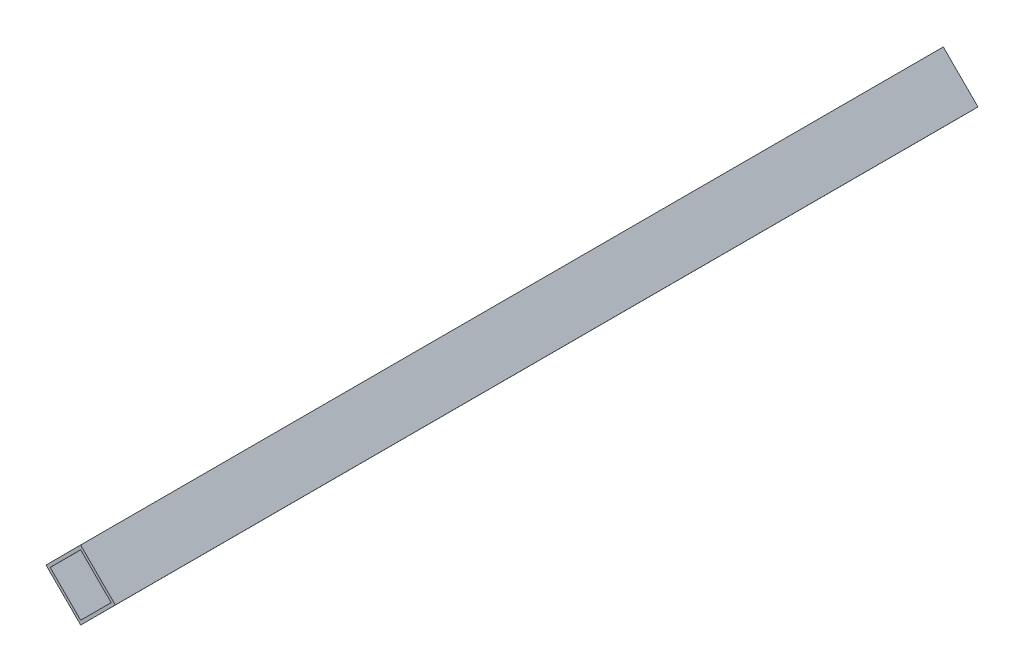
from build123d import *

# Parameters (mm, degrees)
EXTRUDE_1_DEPTH = 440


with BuildPart() as part:
    # 草圖1 → 填料-伸長1 (new body)
    with BuildSketch(Plane.XY):
        Polygon((0, 0), (17.69379362, -17.661530719), (0.032262901, -35.355324339), (-17.661530719, -17.69379362), align=None)
        Polygon((0.001935774, -2.12131946), (-15.540211259, -17.691857846), (0.030327127, -33.234004879), (15.57247416, -17.663466493), align=None, mode=Mode.SUBTRACT)
    extrude(amount=EXTRUDE_1_DEPTH)


solid = part.part
